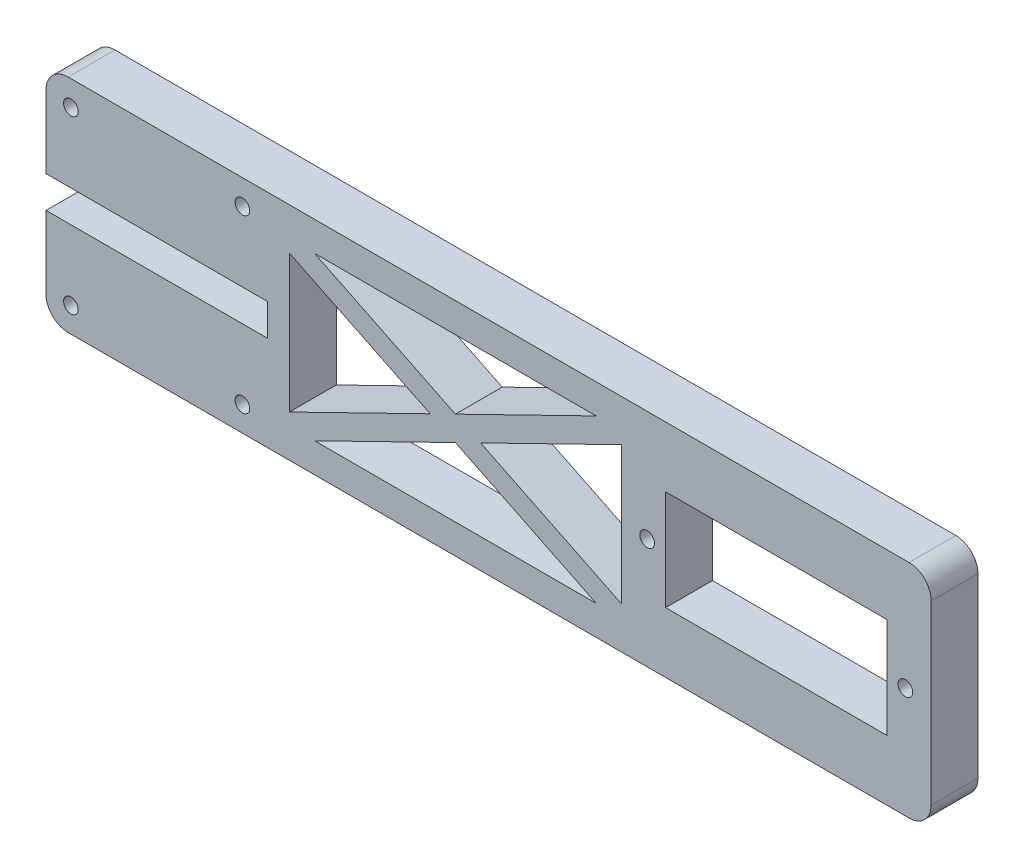
from build123d import *

# Parameters (mm, degrees)
SKETCH1_W                     = 30
SKETCH1_H                     = 13.6
MAIN_SHAPE_DEPTH              = 6.35
SHOULDER_X_MOUNT_HOLES_D      = 1.9939
SHOULDER_X_MOUNT_HOLES_DEPTH  = 7.67
SHOULDER_X_MOUNT_HOLES_TIP    = 0.599027994
ELBOW_SERVO_MOUNT_HOLES_D     = 1.9939
ELBOW_SERVO_MOUNT_HOLES_DEPTH = 7.67
ELBOW_SERVO_MOUNT_HOLES_TIP   = 0.599027994
FILLET2_R                     = 3
WEIGHT_REMOVAL_DEPTH          = 7.35


with BuildPart() as part:
    # Sketch1 → main shape (new body)
    with BuildSketch(Plane.XY):
        Polygon((0, 0), (120, 0), (120, 30), (0, 30), (0, 17.159), (30, 17.159), (30, 12.841), (0, 12.841), align=None)
        with Locations((99, 15)):
            Rectangle(SKETCH1_W, SKETCH1_H, mode=Mode.SUBTRACT)
    extrude(amount=MAIN_SHAPE_DEPTH)

    # shoulder X mount holes
    with Locations(Plane.XY.offset(6.35)):
        with Locations((26.625, 26.625), (26.625, 3.375), (3.375, 3.375), (3.375, 26.625)):
            Hole(SHOULDER_X_MOUNT_HOLES_D / 2, depth=SHOULDER_X_MOUNT_HOLES_DEPTH)
            with Locations((0, 0, -(SHOULDER_X_MOUNT_HOLES_DEPTH + SHOULDER_X_MOUNT_HOLES_TIP / 2))):  # 118° drill point
                Cone(0, SHOULDER_X_MOUNT_HOLES_D / 2, SHOULDER_X_MOUNT_HOLES_TIP, mode=Mode.SUBTRACT)

    # elbow servo mount holes
    with Locations(Plane.XY.offset(6.35)):
        with Locations((81.5, 15), (116.5, 15)):
            Hole(ELBOW_SERVO_MOUNT_HOLES_D / 2, depth=ELBOW_SERVO_MOUNT_HOLES_DEPTH)
            with Locations((0, 0, -(ELBOW_SERVO_MOUNT_HOLES_DEPTH + ELBOW_SERVO_MOUNT_HOLES_TIP / 2))):  # 118° drill point
                Cone(0, ELBOW_SERVO_MOUNT_HOLES_D / 2, ELBOW_SERVO_MOUNT_HOLES_TIP, mode=Mode.SUBTRACT)

    # Fillet2
    fillet2_edges = [part.edges().sort_by_distance(p)[0] for p in [
        (0, 30, 3.175),
        (120, 30, 3.175),
        (120, 0, 3.175),
        (0, 0, 3.175),
    ]]
    fillet(fillet2_edges, radius=FILLET2_R)

    # Sketch8 → weight removal (cut, through all)
    with BuildSketch(Plane.XY):
        Polygon((36.41522176, 26), (55.5, 16.669663972), (74.58477824, 26), align=None)
        Polygon((36.41522176, 4), (74.58477824, 4), (55.5, 13.330336028), align=None)
        Polygon((78, 24.330336028), (78, 5.669663972), (58.91522176, 15), align=None)
        Polygon((33, 24.330336028), (52.08477824, 15), (33, 5.669663972), align=None)
    extrude(amount=WEIGHT_REMOVAL_DEPTH, mode=Mode.SUBTRACT)


solid = part.part
